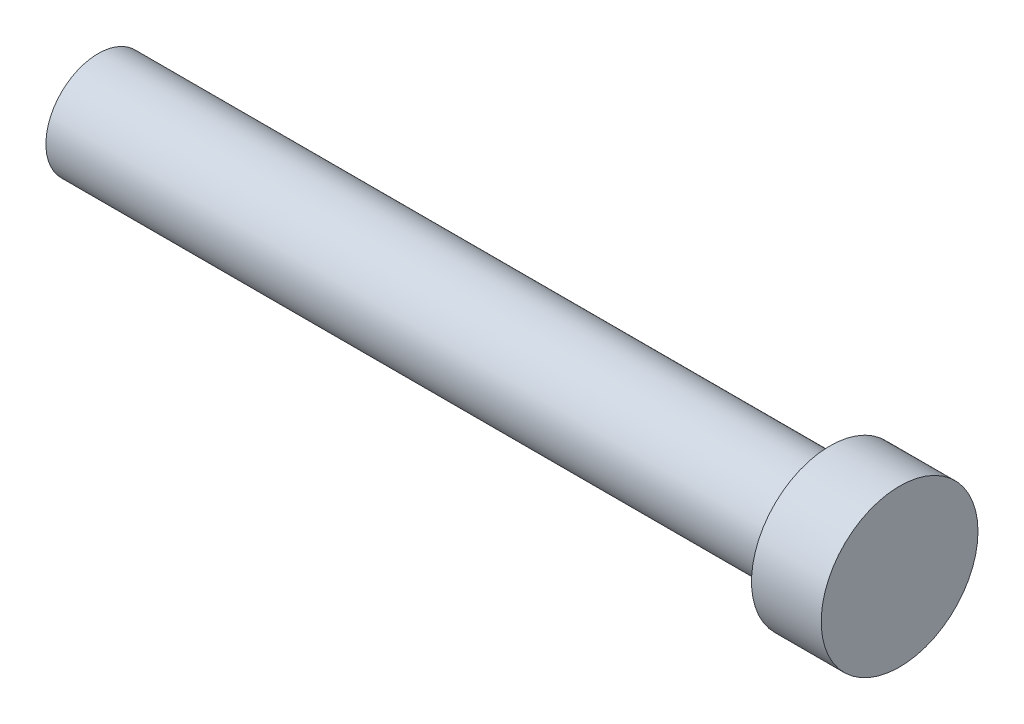
from build123d import *

# Parameters (mm, degrees)
SKETCH2_R           = 15
BOSS_EXTRUDE1_DEPTH = 210
SKETCH3_R           = 22.5
BOSS_EXTRUDE2_DEPTH = 20


with BuildPart() as part:
    # Sketch2 → Boss-Extrude1 (new body)
    with BuildSketch(Plane(origin=(0, 0, 0), x_dir=(0, 0, -1), z_dir=(1, 0, 0))):
        Circle(SKETCH2_R)
    extrude(amount=BOSS_EXTRUDE1_DEPTH)

    # Sketch3 → Boss-Extrude2 (add)
    with BuildSketch(Plane(origin=(210, 0, 0), x_dir=(0, 0, -1), z_dir=(1, 0, 0))):
        Circle(SKETCH3_R)
    extrude(amount=BOSS_EXTRUDE2_DEPTH)


solid = part.part
